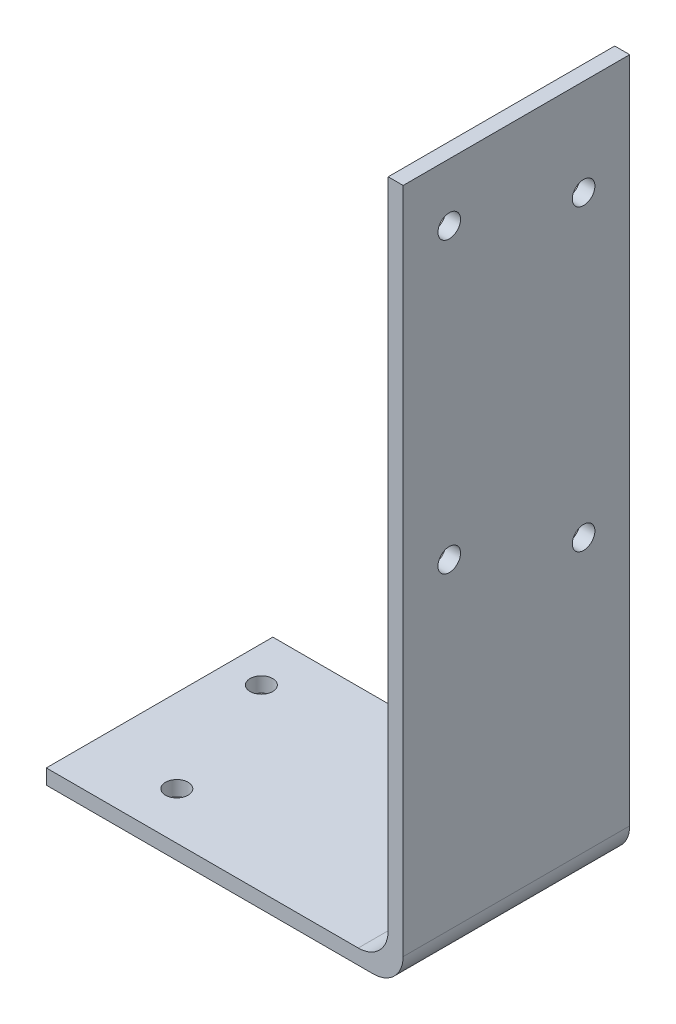
from build123d import *

# Parameters (mm, degrees)
BOSS_EXTRUDE1_DEPTH = 38.4429
SKETCH2_R           = 1.9177
CUT_EXTRUDE1_DEPTH  = 3.54
SKETCH3_R           = 1.9177
CUT_EXTRUDE2_DEPTH  = 3.54
FILLET1_R           = 5.08
SKETCH4_W           = 52.9336
SKETCH4_H           = 38.4429
CUT_EXTRUDE4_DEPTH  = 3.54


with BuildPart() as part:
    # Sketch1 → Boss-Extrude1 (new body)
    with BuildSketch(Plane.XY):
        Polygon((0, 0), (113.4872, 0), (113.4872, 118.4148), (110.9472, 118.4148), (110.9472, 2.54), (0, 2.54), align=None)
    extrude(amount=BOSS_EXTRUDE1_DEPTH)

    # Sketch2 → Cut-Extrude1 (cut, through all)
    with BuildSketch(Plane(origin=(0, 2.54, 0), x_dir=(1, 0, 0), z_dir=(0, 1, 0))):
        with Locations((67.0687, -30.4292)):
            Circle(SKETCH2_R)
        with Locations((59.0042, -8.0137)):
            Circle(SKETCH2_R)
        with Locations((16.2052, -30.4292)):
            Circle(SKETCH2_R)
        with Locations((9.8806, -8.0137)):
            Circle(SKETCH2_R)
    extrude(amount=-CUT_EXTRUDE1_DEPTH, mode=Mode.SUBTRACT)

    # Sketch3 → Cut-Extrude2 (cut, through all)
    with BuildSketch(Plane.ZY.offset(-110.9472)):
        with Locations((7.8232, 51.3842)):
            Circle(SKETCH3_R)
        with Locations((30.6197, 59.5249)):
            Circle(SKETCH3_R)
        with Locations((7.8232, 102.0699)):
            Circle(SKETCH3_R)
        with Locations((30.6197, 108.5723)):
            Circle(SKETCH3_R)
    extrude(amount=-CUT_EXTRUDE2_DEPTH, mode=Mode.SUBTRACT)

    # Fillet1
    fillet1_edges = [part.edges().sort_by_distance(p)[0] for p in [
        (110.9472, 2.54, 19.22145),
        (113.4872, 0, 19.22145),
    ]]
    fillet(fillet1_edges, radius=FILLET1_R)

    # Sketch4 → Cut-Extrude4 (cut, through all)
    with BuildSketch(Plane(origin=(0, 2.54, 0), x_dir=(1, 0, 0), z_dir=(0, 1, 0))):
        with Locations((26.4668, -19.22145)):
            Rectangle(SKETCH4_W, SKETCH4_H)
    extrude(amount=-CUT_EXTRUDE4_DEPTH, mode=Mode.SUBTRACT)


solid = part.part
